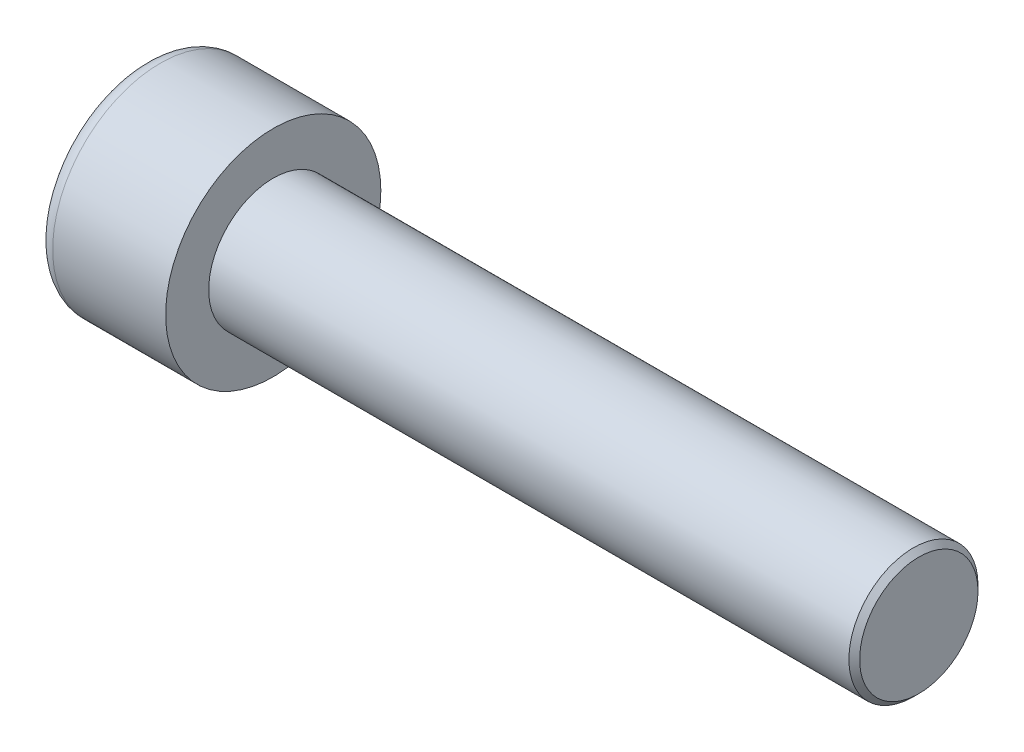
from build123d import *

# Parameters (mm, degrees)
SKETCH1_R           = 5
BASEHEAD_DEPTH      = 6
SKETCH2_R           = 3
BASEBODY_DEPTH      = 30
HEXAGONSOCKET_DEPTH = 3
TOPFILLET_R         = 0.75
CHAMFER1_SIZE       = 0.25


with BuildPart() as part:
    # Sketch1 → BaseHead (new body)
    with BuildSketch(Plane(origin=(0, 0, 0), x_dir=(0, 0, -1), z_dir=(1, 0, 0))):
        Circle(SKETCH1_R)
    extrude(amount=BASEHEAD_DEPTH)

    # Sketch2 → BaseBody (add)
    with BuildSketch(Plane(origin=(6, 0, 0), x_dir=(0, 0, -1), z_dir=(1, 0, 0))):
        Circle(SKETCH2_R)
    extrude(amount=BASEBODY_DEPTH)

    # Sketch3 → HexagonSocket (cut)
    with BuildSketch(Plane(origin=(0, 0, 0), x_dir=(0, 0, -1), z_dir=(1, 0, 0))):
        Polygon((2.886751346, 0), (1.443375673, 2.5), (-1.443375673, 2.5), (-2.886751346, 0), (-1.443375673, -2.5), (1.443375673, -2.5), align=None)
    extrude(amount=HEXAGONSOCKET_DEPTH, mode=Mode.SUBTRACT)

    # Sketch4 → Cut-Revolve1 (revolve, cut)
    with BuildSketch(Plane(origin=(-4.19613823, 0.75, 0), x_dir=(-1, 0, 0), z_dir=(0, 0, 1))):
        Polygon((-7.19613823, 3.25), (-8.639513903, 0.75), (-7.19613823, 0.75), align=None)
    revolve(axis=Axis((0.838992387, 0, 0), (-1, 0, 0)), mode=Mode.SUBTRACT)

    # TopFillet
    topfillet_edges = [part.edges().sort_by_distance(p)[0] for p in [
        (0, 0, 5),
    ]]
    fillet(topfillet_edges, radius=TOPFILLET_R)

    # Chamfer1
    chamfer1_edges = [part.edges().sort_by_distance(p)[0] for p in [
        (36, 0, 3),
    ]]
    chamfer(chamfer1_edges, length=CHAMFER1_SIZE)


solid = part.part
